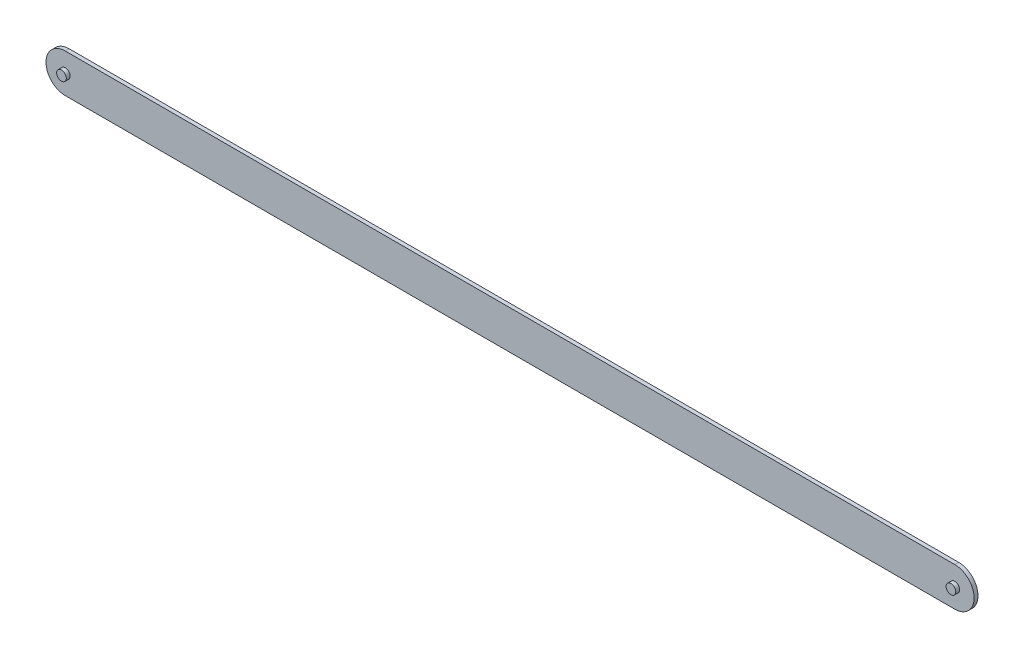
from build123d import *

# Parameters (mm, degrees)
SKETCH2_R           = 3.175
BOSS_EXTRUDE1_DEPTH = 2.54
SKETCH2_3_R         = 3.175
BOSS_EXTRUDE2_DEPTH = 5.08


with BuildPart() as part:
    # Sketch2 → Boss-Extrude1 (new body)
    with BuildSketch(Plane.XY):
        with BuildLine():
            Line((584.2, 25.4), (0, 25.4))
            ThreePointArc((0, 25.4), (-12.7, 12.7), (0, 0))
            Line((0, 0), (584.2, 0))
            ThreePointArc((584.2, 0), (596.9, 12.7), (584.2, 25.4))
        make_face()
        with Locations((0, 12.7)):
            Circle(SKETCH2_R, mode=Mode.SUBTRACT)
        with Locations((584.2, 12.7)):
            Circle(SKETCH2_R, mode=Mode.SUBTRACT)
    extrude(amount=BOSS_EXTRUDE1_DEPTH)

    # Sketch2_3 → Boss-Extrude2 (add)
    with BuildSketch(Plane.XY):
        with Locations((0, 12.7)):
            Circle(SKETCH2_3_R)
        with Locations((584.2, 12.7)):
            Circle(SKETCH2_3_R)
    extrude(amount=BOSS_EXTRUDE2_DEPTH)


solid = part.part
